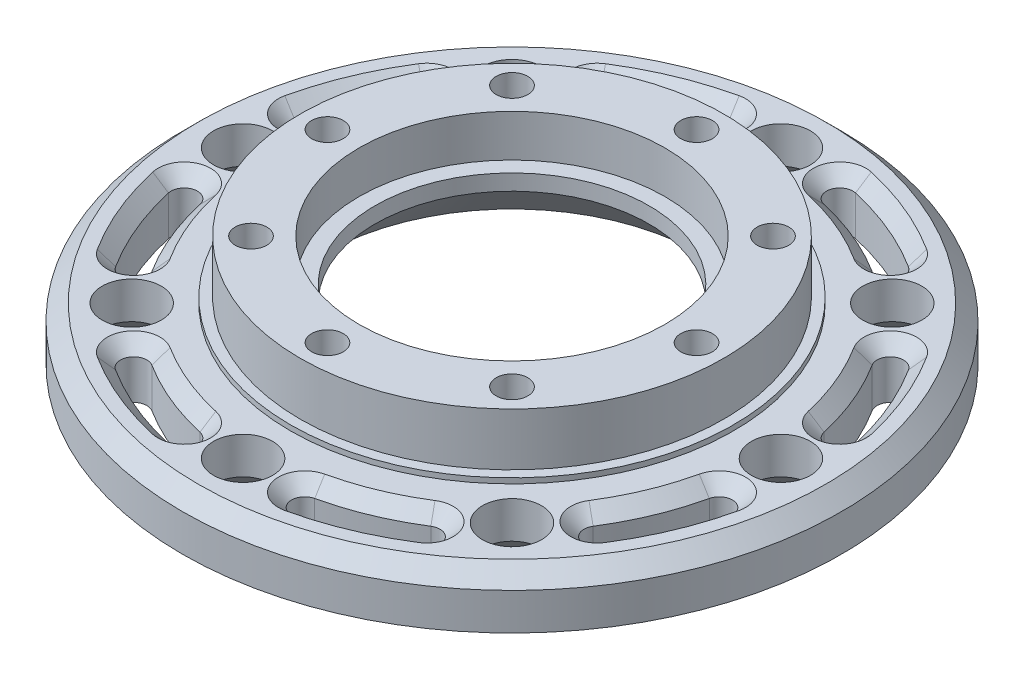
from build123d import *

# Parameters (mm, degrees)
SKETCH1_R            = 62.5
SKETCH1_R_2          = 5.6
SKETCH1_R_3          = 41.5
BOSS_EXTRUDE1_DEPTH  = 10
SKETCH2_R            = 41.5
SKETCH2_R_2          = 3.5
SKETCH2_R_3          = 30
BOSS_EXTRUDE2_DEPTH  = 10
BOSS_EXTRUDE3_START  = -20
SKETCH3_R            = 3.5
BOSS_EXTRUDE3_DEPTH  = 10
SKETCH4_R            = 41.5
SKETCH4_R_2          = 40
CUT_EXTRUDE1_DEPTH   = 10
CHAMFER1_SIZE        = 3
CUT_EXTRUDE4_DEPTH   = 13
BOSS_EXTRUDE4_START  = 1
SKETCH10_R           = 42
SKETCH10_R_2         = 40
BOSS_EXTRUDE4_DEPTH  = 1
BOSS_EXTRUDE9_DEPTH  = 10
SKETCH18_R           = 3.5
BOSS_EXTRUDE10_DEPTH = 10
SKETCH19_R           = 3
CUT_EXTRUDE7_DEPTH   = 5
CUT_EXTRUDE8_DEPTH   = 15
CHAMFER9_SIZE        = 2.5
BOSS_EXTRUDE11_START = -20
SKETCH22_R           = 30
SKETCH22_R_2         = 26
BOSS_EXTRUDE11_DEPTH = 15
SKETCH23_R           = 30
SKETCH23_R_2         = 29
BOSS_EXTRUDE12_DEPTH = 5
CHAMFER10_SIZE       = 10
CUT_EXTRUDE10_START  = -2
SKETCH24_R           = 29
SKETCH24_R_2         = 26
CUT_EXTRUDE10_DEPTH  = 2
BOSS_EXTRUDE13_START = 1
SKETCH25_R           = 40
SKETCH25_R_2         = 29
SKETCH25_R_3         = 3
BOSS_EXTRUDE13_DEPTH = 1
BOSS_EXTRUDE14_START = 10
SKETCH26_R           = 40.15
SKETCH26_R_2         = 40
BOSS_EXTRUDE14_DEPTH = 10
CHAMFER11_SIZE       = 3


with BuildPart() as part:
    # Sketch1 → Boss-Extrude1 (new body)
    with BuildSketch(Plane(origin=(0, 0, 0), x_dir=(1, 0, 0), z_dir=(0, 1, 0))):
        with Locations(Location((0, 0, 0), (0, 0, 270))):
            Circle(SKETCH1_R)
        with Locations(Location((-51, 0, 0), (0, 0, 270))):
            Circle(SKETCH1_R_2, mode=Mode.SUBTRACT)
        with Locations(Location((-36.062445841, 36.062445841, 0), (0, 0, 270))):
            Circle(SKETCH1_R_2, mode=Mode.SUBTRACT)
        with Locations(Location((0, 51, 0), (0, 0, 270))):
            Circle(SKETCH1_R_2, mode=Mode.SUBTRACT)
        with Locations(Location((36.062445841, 36.062445841, 0), (0, 0, 270))):
            Circle(SKETCH1_R_2, mode=Mode.SUBTRACT)
        with Locations(Location((51, 0, 0), (0, 0, 270))):
            Circle(SKETCH1_R_2, mode=Mode.SUBTRACT)
        with Locations(Location((36.062445841, -36.062445841, 0), (0, 0, 270))):
            Circle(SKETCH1_R_2, mode=Mode.SUBTRACT)
        with Locations(Location((0, -51, 0), (0, 0, 270))):
            Circle(SKETCH1_R_2, mode=Mode.SUBTRACT)
        with Locations(Location((-36.062445841, -36.062445841, 0), (0, 0, 270))):
            Circle(SKETCH1_R_2, mode=Mode.SUBTRACT)
        with Locations(Location((0, 0, 0), (0, 0, 270))):
            Circle(SKETCH1_R_3, mode=Mode.SUBTRACT)
    extrude(amount=BOSS_EXTRUDE1_DEPTH)

    # Sketch2 → Boss-Extrude2 (add, symmetric)
    with BuildSketch(Plane(origin=(0, 10, 0), x_dir=(1, 0, 0), z_dir=(0, 1, 0))):
        with Locations(Location((0, 0, 0), (0, 0, 270))):
            Circle(SKETCH2_R)
        with Locations(Location((0, -35, 0), (0, 0, 270))):
            Circle(SKETCH2_R_2, mode=Mode.SUBTRACT)
        with Locations(Location((-24.748737342, -24.748737342, 0), (0, 0, 270))):
            Circle(SKETCH2_R_2, mode=Mode.SUBTRACT)
        with Locations(Location((24.748737342, -24.748737342, 0), (0, 0, 270))):
            Circle(SKETCH2_R_2, mode=Mode.SUBTRACT)
        with Locations(Location((35, 0, 0), (0, 0, 270))):
            Circle(SKETCH2_R_2, mode=Mode.SUBTRACT)
        with BuildLine():
            ThreePointArc((-38.5, 0), (-35, 3.5), (-31.5, 0))
            ThreePointArc((-31.5, 0), (-35, -3.5), (-38.5, 0))
        make_face(mode=Mode.SUBTRACT)
        with Locations(Location((-24.748737342, 24.748737342, 0), (0, 0, 270))):
            Circle(SKETCH2_R_2, mode=Mode.SUBTRACT)
        with Locations(Location((0, 0, 0), (0, 0, 270))):
            Circle(SKETCH2_R_3, mode=Mode.SUBTRACT)
        with Locations(Location((24.748737342, 24.748737342, 0), (0, 0, 270))):
            Circle(SKETCH2_R_2, mode=Mode.SUBTRACT)
        with Locations(Location((0, 35, 0), (0, 0, 270))):
            Circle(SKETCH2_R_2, mode=Mode.SUBTRACT)
    extrude(amount=BOSS_EXTRUDE2_DEPTH, both=True)

    # Sketch3 → Boss-Extrude3 (add)
    with BuildSketch(Plane(origin=(0, 20, 0), x_dir=(1, 0, 0), z_dir=(0, 1, 0)).offset(BOSS_EXTRUDE3_START)):
        with Locations(Location((-35, 0, 0), (0, 0, 270))):
            Circle(SKETCH3_R)
        with Locations(Location((-24.748737342, 24.748737342, 0), (0, 0, 270))):
            Circle(SKETCH3_R)
        with Locations(Location((0, 35, 0), (0, 0, 270))):
            Circle(SKETCH3_R)
        with Locations(Location((24.748737342, 24.748737342, 0), (0, 0, 270))):
            Circle(SKETCH3_R)
        with Locations(Location((35, 0, 0), (0, 0, 270))):
            Circle(SKETCH3_R)
        with Locations(Location((24.748737342, -24.748737342, 0), (0, 0, 270))):
            Circle(SKETCH3_R)
        with Locations(Location((0, -35, 0), (0, 0, 270))):
            Circle(SKETCH3_R)
        with Locations(Location((-24.748737342, -24.748737342, 0), (0, 0, 270))):
            Circle(SKETCH3_R)
    extrude(amount=BOSS_EXTRUDE3_DEPTH)

    # Sketch4 → Cut-Extrude1 (cut)
    with BuildSketch(Plane(origin=(0, 20, 0), x_dir=(1, 0, 0), z_dir=(0, 1, 0))):
        Circle(SKETCH4_R)
        with Locations(Location((0, 0, 0), (0, 0, 270))):
            Circle(SKETCH4_R_2, mode=Mode.SUBTRACT)
    extrude(amount=-CUT_EXTRUDE1_DEPTH, mode=Mode.SUBTRACT)

    # Chamfer1
    chamfer1_edges = [part.edges().sort_by_distance(p)[0] for p in [
        (0, 10, -62.5),
    ]]
    chamfer(chamfer1_edges, length=CHAMFER1_SIZE)

    # Sketch9 → Cut-Extrude4 (cut)
    with BuildSketch(Plane(origin=(0, 10, 0), x_dir=(1, 0, 0), z_dir=(0, 1, 0))):
        with BuildLine():
            ThreePointArc((-45.31509387, 30.2785777), (-50.351434522, 20.856247064), (-53.452797782, 10.63242255))
            ThreePointArc((-53.452797782, 10.63242255), (-51.488560386, 7.692733544), (-48.54887138, 9.65697094))
            ThreePointArc((-48.54887138, 9.65697094), (-45.732036859, 18.942829902), (-41.157745809, 27.500726534))
            ThreePointArc((-41.157745809, 27.500726534), (-41.847494257, 30.968326148), (-45.31509387, 30.2785777))
        make_face()
        with BuildLine():
            ThreePointArc((-10.63242255, 53.452797782), (-20.856247064, 50.351434522), (-30.2785777, 45.31509387))
            ThreePointArc((-30.2785777, 45.31509387), (-30.968326148, 41.847494257), (-27.500726534, 41.157745809))
            ThreePointArc((-27.500726534, 41.157745809), (-18.942829902, 45.732036859), (-9.65697094, 48.54887138))
            ThreePointArc((-9.65697094, 48.54887138), (-7.692733544, 51.488560386), (-10.63242255, 53.452797782))
        make_face()
        with BuildLine():
            ThreePointArc((30.2785777, 45.31509387), (20.856247064, 50.351434522), (10.63242255, 53.452797782))
            ThreePointArc((10.63242255, 53.452797782), (7.692733544, 51.488560386), (9.65697094, 48.54887138))
            ThreePointArc((9.65697094, 48.54887138), (18.942829902, 45.732036859), (27.500726534, 41.157745809))
            ThreePointArc((27.500726534, 41.157745809), (30.968326148, 41.847494257), (30.2785777, 45.31509387))
        make_face()
        with BuildLine():
            ThreePointArc((53.452797782, 10.63242255), (50.351434522, 20.856247064), (45.31509387, 30.2785777))
            ThreePointArc((45.31509387, 30.2785777), (41.847494257, 30.968326148), (41.157745809, 27.500726534))
            ThreePointArc((41.157745809, 27.500726534), (45.732036859, 18.942829902), (48.54887138, 9.65697094))
            ThreePointArc((48.54887138, 9.65697094), (51.488560386, 7.692733544), (53.452797782, 10.63242255))
        make_face()
        with BuildLine():
            ThreePointArc((45.31509387, -30.2785777), (50.351434522, -20.856247064), (53.452797782, -10.63242255))
            ThreePointArc((53.452797782, -10.63242255), (51.488560386, -7.692733544), (48.54887138, -9.65697094))
            ThreePointArc((48.54887138, -9.65697094), (45.732036859, -18.942829902), (41.157745809, -27.500726534))
            ThreePointArc((41.157745809, -27.500726534), (41.847494257, -30.968326148), (45.31509387, -30.2785777))
        make_face()
        with BuildLine():
            ThreePointArc((10.63242255, -53.452797782), (20.856247064, -50.351434522), (30.2785777, -45.31509387))
            ThreePointArc((30.2785777, -45.31509387), (30.968326148, -41.847494257), (27.500726534, -41.157745809))
            ThreePointArc((27.500726534, -41.157745809), (18.942829902, -45.732036859), (9.65697094, -48.54887138))
            ThreePointArc((9.65697094, -48.54887138), (7.692733544, -51.488560386), (10.63242255, -53.452797782))
        make_face()
        with BuildLine():
            ThreePointArc((-30.2785777, -45.31509387), (-20.856247064, -50.351434522), (-10.63242255, -53.452797782))
            ThreePointArc((-10.63242255, -53.452797782), (-7.692733544, -51.488560386), (-9.65697094, -48.54887138))
            ThreePointArc((-9.65697094, -48.54887138), (-18.942829902, -45.732036859), (-27.500726534, -41.157745809))
            ThreePointArc((-27.500726534, -41.157745809), (-30.968326148, -41.847494257), (-30.2785777, -45.31509387))
        make_face()
        with BuildLine():
            ThreePointArc((-53.452797782, -10.63242255), (-50.351434522, -20.856247064), (-45.31509387, -30.2785777))
            ThreePointArc((-45.31509387, -30.2785777), (-41.847494257, -30.968326148), (-41.157745809, -27.500726534))
            ThreePointArc((-41.157745809, -27.500726534), (-45.732036859, -18.942829902), (-48.54887138, -9.65697094))
            ThreePointArc((-48.54887138, -9.65697094), (-51.488560386, -7.692733544), (-53.452797782, -10.63242255))
        make_face()
    extrude(amount=-CUT_EXTRUDE4_DEPTH, mode=Mode.SUBTRACT)

    # Sketch10 → Boss-Extrude4 (add)
    with BuildSketch(Plane(origin=(0, 10, 0), x_dir=(1, 0, 0), z_dir=(0, 1, 0)).offset(BOSS_EXTRUDE4_START)):
        with Locations(Location((0, 0, 0), (0, 0, 270))):
            Circle(SKETCH10_R)
        with Locations(Location((0, 0, 0), (0, 0, 270))):
            Circle(SKETCH10_R_2, mode=Mode.SUBTRACT)
    extrude(amount=-BOSS_EXTRUDE4_DEPTH)

    # Sketch17 → Boss-Extrude9 (add)
    with BuildSketch(Plane(origin=(0, 10, 0), x_dir=(1, 0, 0), z_dir=(0, 1, 0))):
        with BuildLine():
            ThreePointArc((-45.31509387, 30.2785777), (-50.351434522, 20.856247064), (-53.452797782, 10.63242255))
            ThreePointArc((-53.452797782, 10.63242255), (-51.488560386, 7.692733544), (-48.54887138, 9.65697094))
            ThreePointArc((-48.54887138, 9.65697094), (-45.732036859, 18.942829902), (-41.157745809, 27.500726534))
            ThreePointArc((-41.157745809, 27.500726534), (-41.847494257, 30.968326148), (-45.31509387, 30.2785777))
        make_face()
        with BuildLine():
            ThreePointArc((-10.63242255, 53.452797782), (-20.856247064, 50.351434522), (-30.2785777, 45.31509387))
            ThreePointArc((-30.2785777, 45.31509387), (-30.968326148, 41.847494257), (-27.500726534, 41.157745809))
            ThreePointArc((-27.500726534, 41.157745809), (-18.942829902, 45.732036859), (-9.65697094, 48.54887138))
            ThreePointArc((-9.65697094, 48.54887138), (-7.692733544, 51.488560386), (-10.63242255, 53.452797782))
        make_face()
        with BuildLine():
            ThreePointArc((30.2785777, 45.31509387), (20.856247064, 50.351434522), (10.63242255, 53.452797782))
            ThreePointArc((10.63242255, 53.452797782), (7.692733544, 51.488560386), (9.65697094, 48.54887138))
            ThreePointArc((9.65697094, 48.54887138), (18.942829902, 45.732036859), (27.500726534, 41.157745809))
            ThreePointArc((27.500726534, 41.157745809), (30.968326148, 41.847494257), (30.2785777, 45.31509387))
        make_face()
        with BuildLine():
            ThreePointArc((53.452797782, 10.63242255), (50.351434522, 20.856247064), (45.31509387, 30.2785777))
            ThreePointArc((45.31509387, 30.2785777), (41.847494257, 30.968326148), (41.157745809, 27.500726534))
            ThreePointArc((41.157745809, 27.500726534), (45.732036859, 18.942829902), (48.54887138, 9.65697094))
            ThreePointArc((48.54887138, 9.65697094), (51.488560386, 7.692733544), (53.452797782, 10.63242255))
        make_face()
        with BuildLine():
            ThreePointArc((45.31509387, -30.2785777), (50.351434522, -20.856247064), (53.452797782, -10.63242255))
            ThreePointArc((53.452797782, -10.63242255), (51.488560386, -7.692733544), (48.54887138, -9.65697094))
            ThreePointArc((48.54887138, -9.65697094), (45.732036859, -18.942829902), (41.157745809, -27.500726534))
            ThreePointArc((41.157745809, -27.500726534), (41.847494257, -30.968326148), (45.31509387, -30.2785777))
        make_face()
        with BuildLine():
            ThreePointArc((10.63242255, -53.452797782), (20.856247064, -50.351434522), (30.2785777, -45.31509387))
            ThreePointArc((30.2785777, -45.31509387), (30.968326148, -41.847494257), (27.500726534, -41.157745809))
            ThreePointArc((27.500726534, -41.157745809), (18.942829902, -45.732036859), (9.65697094, -48.54887138))
            ThreePointArc((9.65697094, -48.54887138), (7.692733544, -51.488560386), (10.63242255, -53.452797782))
        make_face()
        with BuildLine():
            ThreePointArc((-30.2785777, -45.31509387), (-20.856247064, -50.351434522), (-10.63242255, -53.452797782))
            ThreePointArc((-10.63242255, -53.452797782), (-7.692733544, -51.488560386), (-9.65697094, -48.54887138))
            ThreePointArc((-9.65697094, -48.54887138), (-18.942829902, -45.732036859), (-27.500726534, -41.157745809))
            ThreePointArc((-27.500726534, -41.157745809), (-30.968326148, -41.847494257), (-30.2785777, -45.31509387))
        make_face()
        with BuildLine():
            ThreePointArc((-53.452797782, -10.63242255), (-50.351434522, -20.856247064), (-45.31509387, -30.2785777))
            ThreePointArc((-45.31509387, -30.2785777), (-41.847494257, -30.968326148), (-41.157745809, -27.500726534))
            ThreePointArc((-41.157745809, -27.500726534), (-45.732036859, -18.942829902), (-48.54887138, -9.65697094))
            ThreePointArc((-48.54887138, -9.65697094), (-51.488560386, -7.692733544), (-53.452797782, -10.63242255))
        make_face()
    extrude(amount=-BOSS_EXTRUDE9_DEPTH)

    # Sketch18 → Boss-Extrude10 (add)
    with BuildSketch(Plane(origin=(0, 10, 0), x_dir=(1, 0, 0), z_dir=(0, 1, 0))):
        with Locations((0, 35)):
            Circle(SKETCH18_R)
        with Locations((24.748737342, 24.748737342)):
            Circle(SKETCH18_R)
        with Locations((35, 0)):
            Circle(SKETCH18_R)
        with Locations((24.748737342, -24.748737342)):
            Circle(SKETCH18_R)
        with Locations((0, -35)):
            Circle(SKETCH18_R)
        with Locations((-24.748737342, -24.748737342)):
            Circle(SKETCH18_R)
        with Locations((-35, 0)):
            Circle(SKETCH18_R)
        with Locations((-24.748737342, 24.748737342)):
            Circle(SKETCH18_R)
    extrude(amount=BOSS_EXTRUDE10_DEPTH)

    # Sketch19 → Cut-Extrude7 (cut)
    with BuildSketch(Plane(origin=(0, 20, 0), x_dir=(1, 0, 0), z_dir=(0, 1, 0))):
        with Locations(Location((-24.748737342, 24.748737342, 0), (0, 0, 270))):
            Circle(SKETCH19_R)
        with Locations(Location((0, 35, 0), (0, 0, 270))):
            Circle(SKETCH19_R)
        with Locations(Location((35, 0, 0), (0, 0, 270))):
            Circle(SKETCH19_R)
        with Locations(Location((24.748737342, -24.748737342, 0), (0, 0, 270))):
            Circle(SKETCH19_R)
        with Locations(Location((0, -35, 0), (0, 0, 270))):
            Circle(SKETCH19_R)
        with Locations(Location((-24.748737342, -24.748737342, 0), (0, 0, 270))):
            Circle(SKETCH19_R)
        with BuildLine():
            ThreePointArc((-38, 0), (-35, -3), (-32, 0))
            Line((-32, 0), (-38, 0))
        make_face()
        with BuildLine():
            Line((-38, 0), (-32, 0))
            ThreePointArc((-32, 0), (-35, 3), (-38, 0))
        make_face()
        with Locations(Location((24.748737342, 24.748737342, 0), (0, 0, 270))):
            Circle(SKETCH19_R)
    extrude(amount=-CUT_EXTRUDE7_DEPTH, mode=Mode.SUBTRACT)

    # Sketch20 → Cut-Extrude8 (cut)
    with BuildSketch(Plane(origin=(0, 10, 0), x_dir=(1, 0, 0), z_dir=(0, 1, 0))):
        with BuildLine():
            ThreePointArc((-46.065319954, 29.124496521), (-50.351434522, 20.856247064), (-53.167229105, 11.978971128))
            ThreePointArc((-53.167229105, 11.978971128), (-51.277859473, 8.990613319), (-48.289501664, 10.879982951))
            ThreePointArc((-48.289501664, 10.879982951), (-45.732036859, 18.942829902), (-41.839143811, 26.452524363))
            ThreePointArc((-41.839143811, 26.452524363), (-42.616245803, 29.901598513), (-46.065319954, 29.124496521))
        make_face()
        with BuildLine():
            ThreePointArc((-11.978971128, 53.167229105), (-20.856247064, 50.351434522), (-29.124496521, 46.065319954))
            ThreePointArc((-29.124496521, 46.065319954), (-29.901598513, 42.616245803), (-26.452524363, 41.839143811))
            ThreePointArc((-26.452524363, 41.839143811), (-18.942829902, 45.732036859), (-10.879982951, 48.289501664))
            ThreePointArc((-10.879982951, 48.289501664), (-8.990613319, 51.277859473), (-11.978971128, 53.167229105))
        make_face()
        with BuildLine():
            ThreePointArc((29.124496521, 46.065319954), (20.856247064, 50.351434522), (11.978971128, 53.167229105))
            ThreePointArc((11.978971128, 53.167229105), (8.990613319, 51.277859473), (10.879982951, 48.289501664))
            ThreePointArc((10.879982951, 48.289501664), (18.942829902, 45.732036859), (26.452524363, 41.839143811))
            ThreePointArc((26.452524363, 41.839143811), (29.901598513, 42.616245803), (29.124496521, 46.065319954))
        make_face()
        with BuildLine():
            ThreePointArc((53.167229105, 11.978971128), (50.351434522, 20.856247064), (46.065319954, 29.124496521))
            ThreePointArc((46.065319954, 29.124496521), (42.616245803, 29.901598513), (41.839143811, 26.452524363))
            ThreePointArc((41.839143811, 26.452524363), (45.732036859, 18.942829902), (48.289501664, 10.879982951))
            ThreePointArc((48.289501664, 10.879982951), (51.277859473, 8.990613319), (53.167229105, 11.978971128))
        make_face()
        with BuildLine():
            ThreePointArc((46.065319954, -29.124496521), (50.351434522, -20.856247064), (53.167229105, -11.978971128))
            ThreePointArc((53.167229105, -11.978971128), (51.277859473, -8.990613319), (48.289501664, -10.879982951))
            ThreePointArc((48.289501664, -10.879982951), (45.732036859, -18.942829902), (41.839143811, -26.452524363))
            ThreePointArc((41.839143811, -26.452524363), (42.616245803, -29.901598513), (46.065319954, -29.124496521))
        make_face()
        with BuildLine():
            ThreePointArc((11.978971128, -53.167229105), (20.856247064, -50.351434522), (29.124496521, -46.065319954))
            ThreePointArc((29.124496521, -46.065319954), (29.901598513, -42.616245803), (26.452524363, -41.839143811))
            ThreePointArc((26.452524363, -41.839143811), (18.942829902, -45.732036859), (10.879982951, -48.289501664))
            ThreePointArc((10.879982951, -48.289501664), (8.990613319, -51.277859473), (11.978971128, -53.167229105))
        make_face()
        with BuildLine():
            ThreePointArc((-29.124496521, -46.065319954), (-20.856247064, -50.351434522), (-11.978971128, -53.167229105))
            ThreePointArc((-11.978971128, -53.167229105), (-8.990613319, -51.277859473), (-10.879982951, -48.289501664))
            ThreePointArc((-10.879982951, -48.289501664), (-18.942829902, -45.732036859), (-26.452524363, -41.839143811))
            ThreePointArc((-26.452524363, -41.839143811), (-29.901598513, -42.616245803), (-29.124496521, -46.065319954))
        make_face()
        with BuildLine():
            ThreePointArc((-53.167229105, -11.978971128), (-50.351434522, -20.856247064), (-46.065319954, -29.124496521))
            ThreePointArc((-46.065319954, -29.124496521), (-42.616245803, -29.901598513), (-41.839143811, -26.452524363))
            ThreePointArc((-41.839143811, -26.452524363), (-45.732036859, -18.942829902), (-48.289501664, -10.879982951))
            ThreePointArc((-48.289501664, -10.879982951), (-51.277859473, -8.990613319), (-53.167229105, -11.978971128))
        make_face()
    extrude(amount=-CUT_EXTRUDE8_DEPTH, mode=Mode.SUBTRACT)

    # Chamfer9
    chamfer9_edges = [part.edges().sort_by_distance(p)[0] for p in [
        (-8.990613319, 10, -51.277859473),
        (-20.856247064, 10, -50.351434522),
        (-29.901598513, 10, -42.616245803),
        (-18.942829902, 10, -45.732036859),
        (29.901598513, 10, -42.616245803),
        (20.856247064, 10, -50.351434522),
        (8.990613319, 10, -51.277859473),
        (18.942829902, 10, -45.732036859),
        (51.277859473, 10, -8.990613319),
        (50.351434522, 10, -20.856247064),
        (42.616245803, 10, -29.901598513),
        (45.732036859, 10, -18.942829902),
        (42.616245803, 10, 29.901598513),
        (50.351434522, 10, 20.856247064),
        (51.277859473, 10, 8.990613319),
        (45.732036859, 10, 18.942829902),
        (8.990613319, 10, 51.277859473),
        (20.856247064, 10, 50.351434522),
        (29.901598513, 10, 42.616245803),
        (18.942829902, 10, 45.732036859),
        (-29.901598513, 10, 42.616245803),
        (-20.856247064, 10, 50.351434522),
        (-8.990613319, 10, 51.277859473),
        (-18.942829902, 10, 45.732036859),
        (-51.277859473, 10, 8.990613319),
        (-50.351434522, 10, 20.856247064),
        (-42.616245803, 10, 29.901598513),
        (-45.732036859, 10, 18.942829902),
        (-42.616245803, 10, -29.901598513),
        (-50.351434522, 10, -20.856247064),
        (-51.277859473, 10, -8.990613319),
        (-45.732036859, 10, -18.942829902),
    ]]
    chamfer(chamfer9_edges, length=CHAMFER9_SIZE)

    # Sketch22 → Boss-Extrude11 (add)
    with BuildSketch(Plane(origin=(0, 20, 0), x_dir=(1, 0, 0), z_dir=(0, 1, 0)).offset(BOSS_EXTRUDE11_START)):
        with Locations(Location((0, 0, 0), (0, 0, 270))):
            Circle(SKETCH22_R)
        with Locations(Location((0, 0, 0), (0, 0, 270))):
            Circle(SKETCH22_R_2, mode=Mode.SUBTRACT)
    extrude(amount=BOSS_EXTRUDE11_DEPTH)

    # Sketch23 → Boss-Extrude12 (add)
    with BuildSketch(Plane(origin=(0, 15, 0), x_dir=(1, 0, 0), z_dir=(0, 1, 0))):
        Circle(SKETCH23_R)
        with Locations(Location((0, 0, 0), (0, 0, 270))):
            Circle(SKETCH23_R_2, mode=Mode.SUBTRACT)
    extrude(amount=BOSS_EXTRUDE12_DEPTH)

    # Chamfer10
    chamfer10_edges = [part.edges().sort_by_distance(p)[0] for p in [
        (0, 0, -26),
    ]]
    chamfer(chamfer10_edges, length=CHAMFER10_SIZE)

    # Sketch24 → Cut-Extrude10 (cut)
    with BuildSketch(Plane(origin=(0, 15, 0), x_dir=(1, 0, 0), z_dir=(0, 1, 0)).offset(CUT_EXTRUDE10_START)):
        with Locations(Location((0, 0, 0), (0, 0, 270))):
            Circle(SKETCH24_R)
        with Locations(Location((0, 0, 0), (0, 0, 270))):
            Circle(SKETCH24_R_2, mode=Mode.SUBTRACT)
    extrude(amount=CUT_EXTRUDE10_DEPTH, mode=Mode.SUBTRACT)

    # Sketch25 → Boss-Extrude13 (add)
    with BuildSketch(Plane(origin=(0, 20, 0), x_dir=(1, 0, 0), z_dir=(0, 1, 0)).offset(BOSS_EXTRUDE13_START)):
        with Locations(Location((0, 0, 0), (0, 0, 270))):
            Circle(SKETCH25_R)
        with Locations(Location((0, 0, 0), (0, 0, 270))):
            Circle(SKETCH25_R_2, mode=Mode.SUBTRACT)
        with Locations(Location((-24.748737342, 24.748737342, 0), (0, 0, 270))):
            Circle(SKETCH25_R_3, mode=Mode.SUBTRACT)
        with Locations(Location((0, 35, 0), (0, 0, 270))):
            Circle(SKETCH25_R_3, mode=Mode.SUBTRACT)
        with Locations(Location((24.748737342, 24.748737342, 0), (0, 0, 270))):
            Circle(SKETCH25_R_3, mode=Mode.SUBTRACT)
        with Locations(Location((35, 0, 0), (0, 0, 270))):
            Circle(SKETCH25_R_3, mode=Mode.SUBTRACT)
        with Locations(Location((24.748737342, -24.748737342, 0), (0, 0, 270))):
            Circle(SKETCH25_R_3, mode=Mode.SUBTRACT)
        with Locations(Location((0, -35, 0), (0, 0, 270))):
            Circle(SKETCH25_R_3, mode=Mode.SUBTRACT)
        with Locations(Location((-24.748737342, -24.748737342, 0), (0, 0, 270))):
            Circle(SKETCH25_R_3, mode=Mode.SUBTRACT)
        with Locations(Location((-35, 0, 0), (0, 0, 270))):
            Circle(SKETCH25_R_3, mode=Mode.SUBTRACT)
    extrude(amount=-BOSS_EXTRUDE13_DEPTH)

    # Sketch26 → Boss-Extrude14 (add)
    with BuildSketch(Plane(origin=(0, 11, 0), x_dir=(1, 0, 0), z_dir=(0, 1, 0)).offset(BOSS_EXTRUDE14_START)):
        with Locations(Location((0, 0, 0), (0, 0, 270))):
            Circle(SKETCH26_R)
        Circle(SKETCH26_R_2, mode=Mode.SUBTRACT)
    extrude(amount=-BOSS_EXTRUDE14_DEPTH)

    # Chamfer11
    chamfer11_edges = [part.edges().sort_by_distance(p)[0] for p in [
        (-36.062445841, 0, 30.462445841),
        (-51, 0, -5.6),
        (-36.062445841, 0, -41.662445841),
        (0, 0, -56.6),
        (36.062445841, 0, -41.662445841),
        (51, 0, -5.6),
        (36.062445841, 0, 30.462445841),
        (0, 0, 45.4),
    ]]
    chamfer(chamfer11_edges, length=CHAMFER11_SIZE)


solid = part.part
